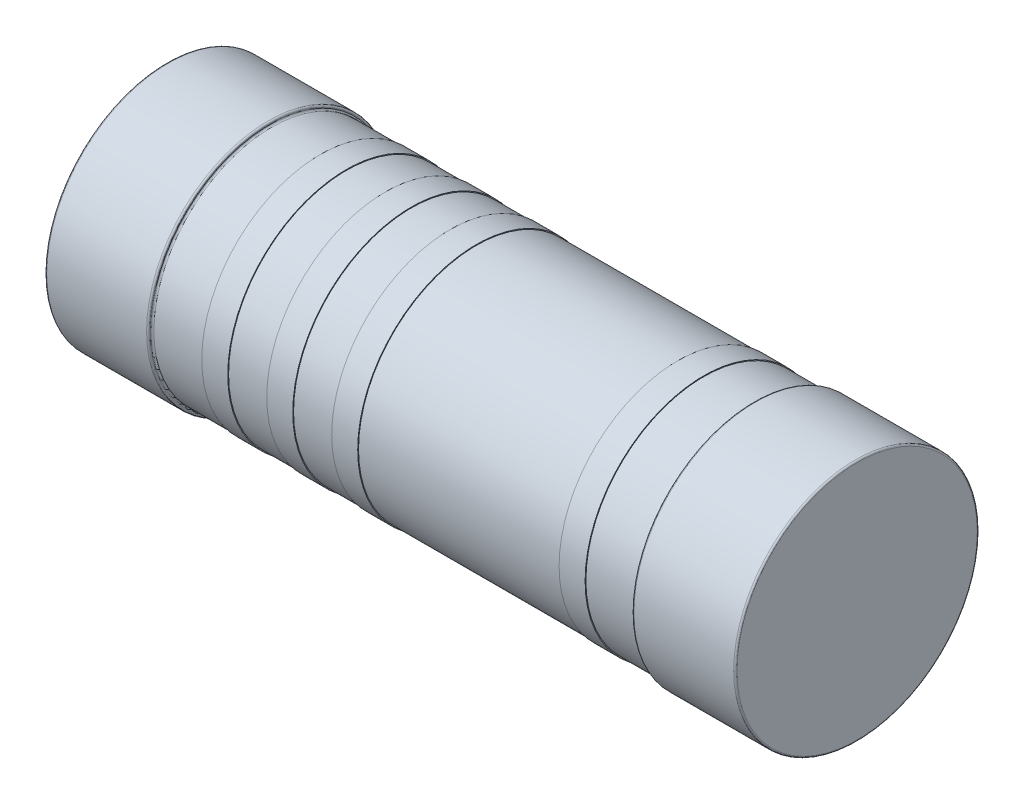
from build123d import *


with BuildPart() as part:
    # Sketch1 → Revolve1 (revolve)
    with BuildSketch(Plane.XY):
        with BuildLine():
            Line((-4.25, 1.5), (4.25, 1.5))
            Line((4.25, 1.5), (4.25, 0.02))
            ThreePointArc((4.25, 0.02), (4.244142136, 0.005857864), (4.23, 0))
            Line((4.23, 0), (3, 0))
            ThreePointArc((3, 0), (2.985857864, 0.005857864), (2.98, 0.02))
            Line((2.98, 0.02), (2.98, 0.03))
            ThreePointArc((2.98, 0.03), (2.974142136, 0.044142136), (2.96, 0.05))
            Line((2.96, 0.05), (2.36, 0.05))
            Line((2.36, 0.05), (2.36, 0.04))
            Line((2.36, 0.04), (2.04, 0.04))
            Line((2.04, 0.04), (2.04, 0.05))
            Line((2.04, 0.05), (-0.44, 0.05))
            Line((-0.44, 0.05), (-0.44, 0.04))
            Line((-0.44, 0.04), (-0.76, 0.04))
            Line((-0.76, 0.04), (-0.76, 0.05))
            Line((-0.76, 0.05), (-1.24, 0.05))
            Line((-1.24, 0.05), (-1.24, 0.04))
            Line((-1.24, 0.04), (-1.56, 0.04))
            Line((-1.56, 0.04), (-1.56, 0.05))
            Line((-1.56, 0.05), (-2.04, 0.05))
            Line((-2.04, 0.05), (-2.04, 0.04))
            Line((-2.04, 0.04), (-2.36, 0.04))
            Line((-2.36, 0.04), (-2.36, 0.05))
            Line((-2.36, 0.05), (-2.96, 0.05))
            ThreePointArc((-2.96, 0.05), (-2.974142136, 0.044142136), (-2.98, 0.03))
            Line((-2.98, 0.03), (-2.98, 0.02))
            ThreePointArc((-2.98, 0.02), (-2.985857864, 0.005857864), (-3, 0))
            Line((-3, 0), (-4.23, 0))
            ThreePointArc((-4.23, 0), (-4.244142136, 0.005857864), (-4.25, 0.02))
            Line((-4.25, 0.02), (-4.25, 1.5))
        make_face()
    revolve(axis=Axis((-4.25, 1.5, 0), (1, 0, 0)))


solid = part.part
